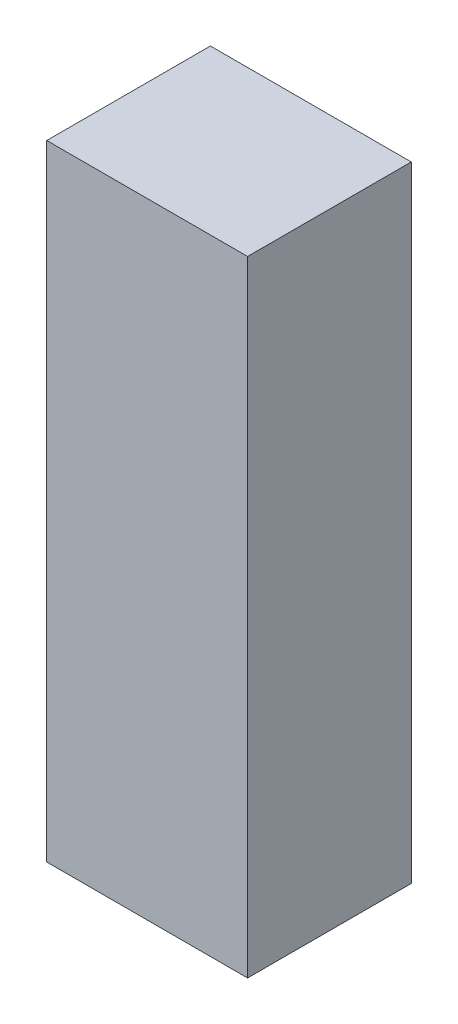
from build123d import *

# Parameters (mm, degrees)
SKETCH1_W           = 685.8
SKETCH1_H           = 558.8
BOSS_EXTRUDE1_DEPTH = 2133.6
SHELL1_T            = -3.175


with BuildPart() as part:
    # Sketch1 → Boss-Extrude1 (new body)
    with BuildSketch(Plane(origin=(0, 0, 0), x_dir=(1, 0, 0), z_dir=(0, 1, 0))):
        Rectangle(SKETCH1_W, SKETCH1_H)
    extrude(amount=BOSS_EXTRUDE1_DEPTH)

    # Shell1
    shell1_openings = [part.faces().sort_by_distance(p)[0] for p in [
        (0, 1066.8, -279.4),
    ]]
    offset(amount=SHELL1_T, openings=shell1_openings, kind=Kind.INTERSECTION)


solid = part.part
